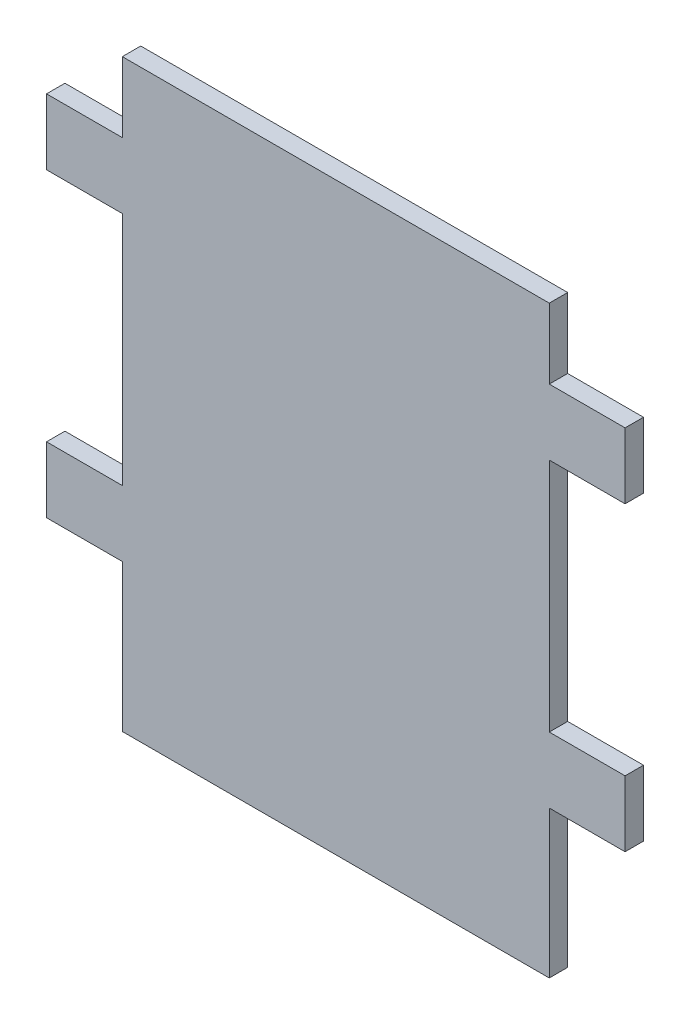
from build123d import *

# Parameters (mm, degrees)
SKETCH1_W           = 99.8200188
SKETCH1_H           = 100.8399812
BOSS_EXTRUDE1_DEPTH = 3.175
SKETCH3_W           = 13.0800094
SKETCH3_H           = 12.1000012
SKETCH3_H_2         = 40.64
SKETCH3_H_3         = 25.4
CUT_EXTRUDE1_DEPTH  = 3.175


with BuildPart() as part:
    # Sketch1 → Boss-Extrude1 (new body)
    with BuildSketch(Plane.XY):
        with Locations((1.240427696, 14.974660495)):
            Rectangle(SKETCH1_W, SKETCH1_H)
    extrude(amount=BOSS_EXTRUDE1_DEPTH)

    # Sketch3 → Cut-Extrude1 (cut)
    with BuildSketch(Plane.XY.offset(3.175)):
        with Locations((-42.129577004, 59.344650495)):
            Rectangle(SKETCH3_W, SKETCH3_H)
        with Locations((44.610432396, 59.344650495)):
            Rectangle(SKETCH3_W, SKETCH3_H)
        with Locations((-42.129577004, 21.624659895)):
            Rectangle(SKETCH3_W, SKETCH3_H_2)
        with Locations((-42.129577004, -22.745330105)):
            Rectangle(SKETCH3_W, SKETCH3_H_3)
        with Locations((44.610432396, 21.624659895)):
            Rectangle(SKETCH3_W, SKETCH3_H_2)
        with Locations((44.610432396, -22.745330105)):
            Rectangle(SKETCH3_W, SKETCH3_H_3)
    extrude(amount=-CUT_EXTRUDE1_DEPTH, mode=Mode.SUBTRACT)


solid = part.part
